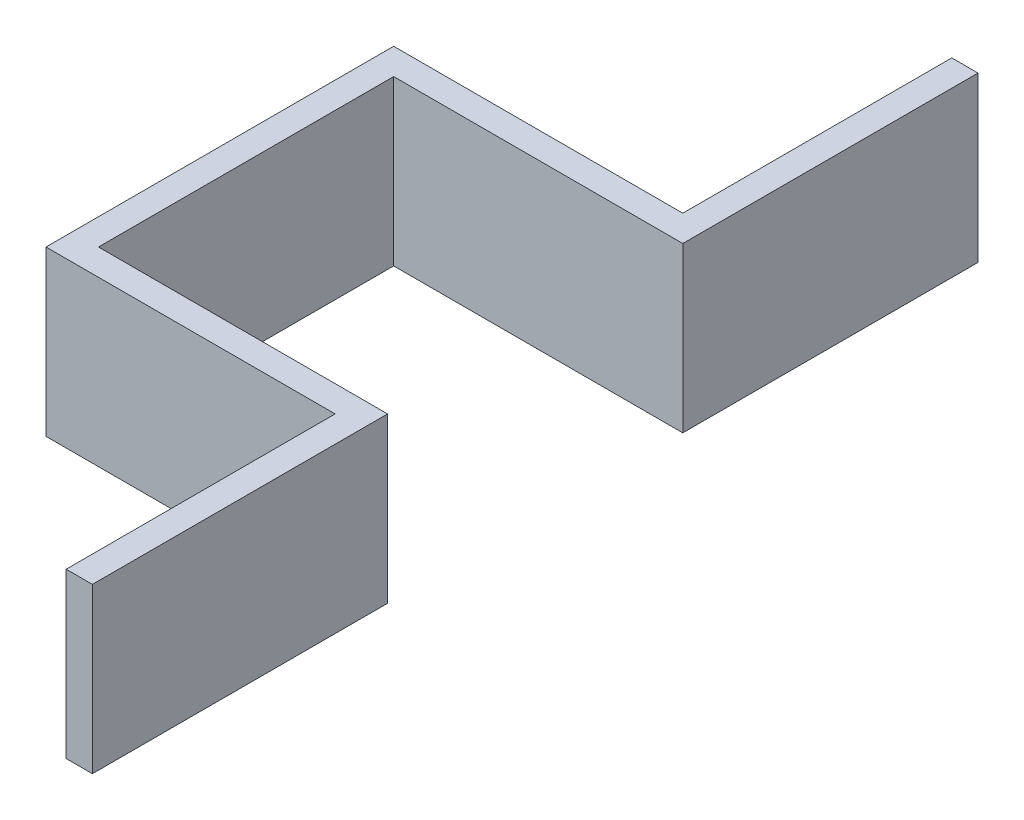
from build123d import *

# Parameters (mm, degrees)
BOSS_EXTRUDE1_DEPTH = 25


with BuildPart() as part:
    # Sketch1 → Boss-Extrude1 (new body)
    with BuildSketch(Plane(origin=(0, 5, 0), x_dir=(1, 0, 0), z_dir=(0, 1, 0))):
        Polygon((-194.102258895, 167.5), (-190.102258895, 167.5), (-190.102258895, 212.5), (-234.174494692, 212.5), (-234.174494692, 257.5), (-190.102258895, 257.5), (-190.102258895, 302.5), (-194.102258895, 302.5), (-194.102258895, 261.5), (-238.174494692, 261.5), (-238.174494692, 208.5), (-194.102258895, 208.5), align=None)
    extrude(amount=-BOSS_EXTRUDE1_DEPTH)


solid = part.part
